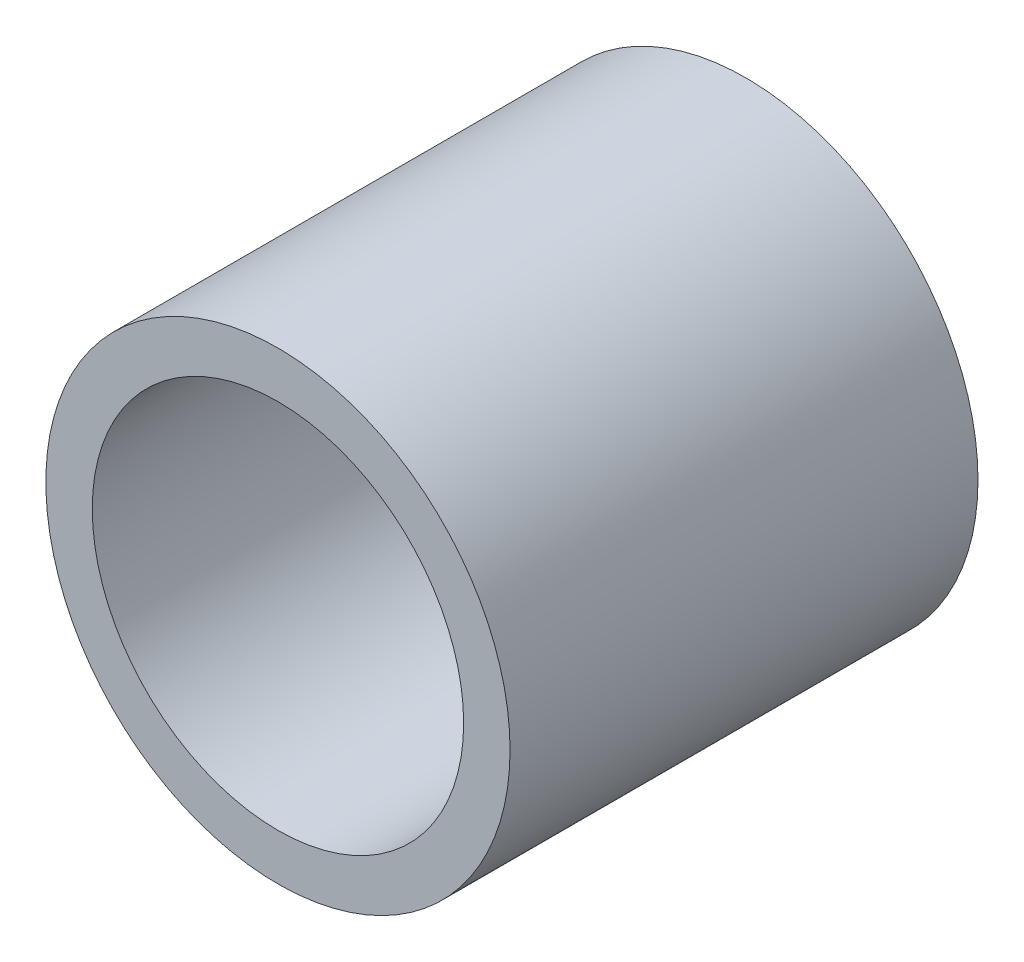
from build123d import *

# Parameters (mm, degrees)
SKETCH1_R           = 7.9375
SKETCH1_R_2         = 6.35
BOSS_EXTRUDE1_DEPTH = 8.001


with BuildPart() as part:
    # Sketch1 → Boss-Extrude1 (new body, symmetric)
    with BuildSketch(Plane.XY):
        Circle(SKETCH1_R)
        Circle(SKETCH1_R_2, mode=Mode.SUBTRACT)
    extrude(amount=BOSS_EXTRUDE1_DEPTH, both=True)


solid = part.part
